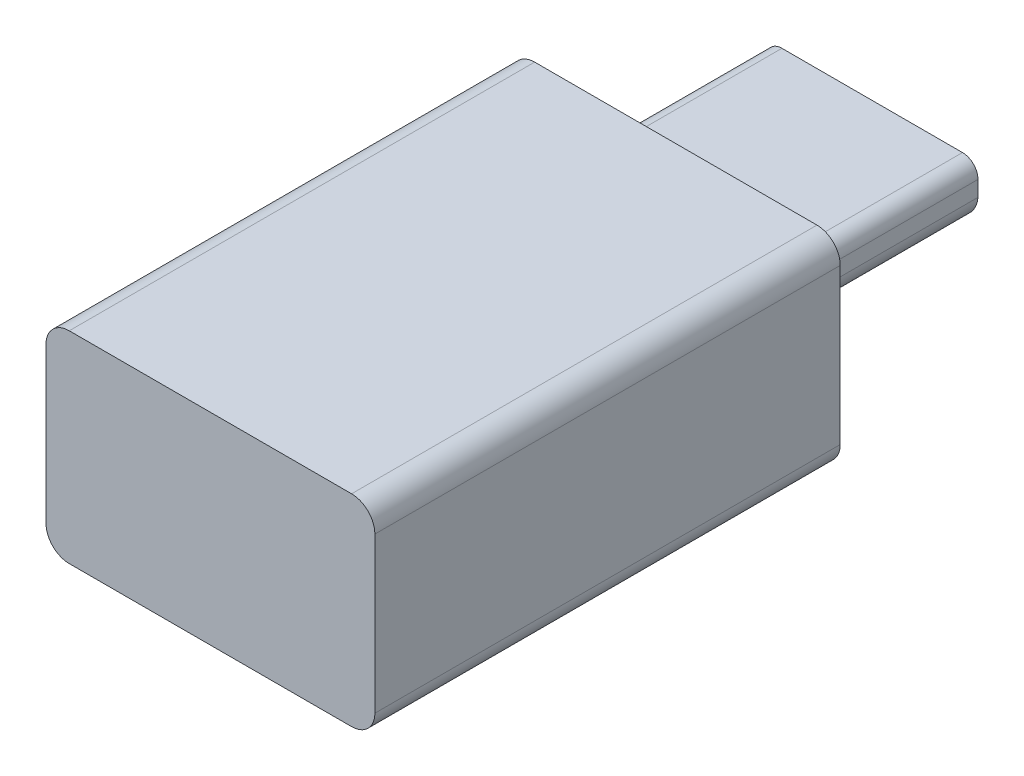
from build123d import *

# Parameters (mm, degrees)
BOSS_EXTRUDE1_DEPTH = 15
BOSS_EXTRUDE2_DEPTH = 6.33


with BuildPart() as part:
    # Sketch1 → Boss-Extrude1 (new body)
    with BuildSketch(Plane(origin=(0, 0, 87.601912264), x_dir=(-1, 0, 0), z_dir=(0, 0, -1))):
        with BuildLine():
            Line((38.270660543, 36.840565439), (47.370660543, 36.840565439))
            ThreePointArc((47.370660543, 36.840565439), (47.900990629, 36.620895525), (48.120660543, 36.090565439))
            Line((48.120660543, 36.090565439), (48.120660543, 31.090565439))
            ThreePointArc((48.120660543, 31.090565439), (47.900990629, 30.560235353), (47.370660543, 30.340565439))
            Line((47.370660543, 30.340565439), (38.270660543, 30.340565439))
            ThreePointArc((38.270660543, 30.340565439), (37.740330458, 30.560235353), (37.520660543, 31.090565439))
            Line((37.520660543, 31.090565439), (37.520660543, 36.090565439))
            ThreePointArc((37.520660543, 36.090565439), (37.740330458, 36.620895525), (38.270660543, 36.840565439))
        make_face()
    extrude(amount=BOSS_EXTRUDE1_DEPTH)

    # Sketch2 → Boss-Extrude2 (add)
    with BuildSketch(Plane(origin=(0, 0, 72.601912264), x_dir=(-1, 0, 0), z_dir=(0, 0, -1))):
        with BuildLine():
            ThreePointArc((40.320660543, 33.050565439), (39.704827774, 33.289230716), (39.410660543, 33.880565439))
            Line((39.410660543, 33.880565439), (39.410660543, 34.380565439))
            ThreePointArc((39.410660543, 34.380565439), (39.557107153, 34.73411883), (39.910660543, 34.880565439))
            Line((39.910660543, 34.880565439), (45.730660543, 34.880565439))
            ThreePointArc((45.730660543, 34.880565439), (46.084213934, 34.73411883), (46.230660543, 34.380565439))
            Line((46.230660543, 34.380565439), (46.230660543, 33.880565439))
            ThreePointArc((46.230660543, 33.880565439), (45.936493313, 33.289230716), (45.320660543, 33.050565439))
            Line((45.320660543, 33.050565439), (40.320660543, 33.050565439))
        make_face()
    extrude(amount=BOSS_EXTRUDE2_DEPTH)


solid = part.part
